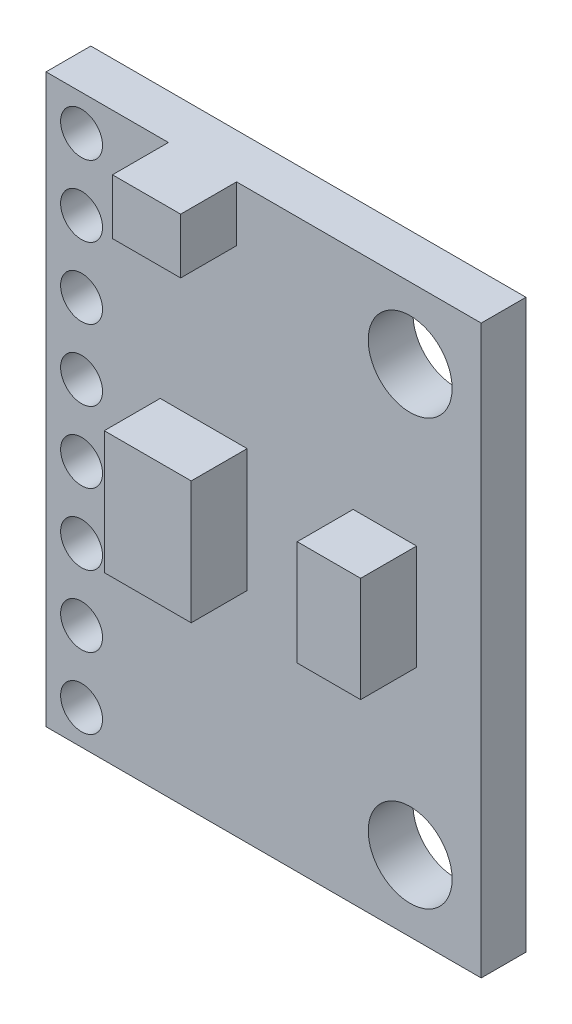
from build123d import *

# Parameters (mm, degrees)
SKETCH_1_W      = 15.56
SKETCH_1_H      = 20.28
SKETCH_1_R      = 1.5
SKETCH_1_R_2    = 0.75
EXTRUDE_1_DEPTH = 1.6
SKETCH_2_W      = 2.267131812
SKETCH_2_H      = 3.757883692
SKETCH_2_W_2    = 3.109101674
SKETCH_2_H_2    = 4.394457387
SKETCH_2_W_3    = 2.437826046
SKETCH_2_H_3    = 1.976096162
EXTRUDE_2_DEPTH = 2


with BuildPart() as part:
    # 草图1 → 凸台-拉伸1 (new body)
    with BuildSketch(Plane.XY):
        Rectangle(SKETCH_1_W, SKETCH_1_H)
        with Locations((5.24, 7.6)):
            Circle(SKETCH_1_R, mode=Mode.SUBTRACT)
        with Locations((5.24, -7.6)):
            Circle(SKETCH_1_R, mode=Mode.SUBTRACT)
        with Locations((-6.51, 8.87)):
            Circle(SKETCH_1_R_2, mode=Mode.SUBTRACT)
        with Locations((-6.51, 6.33)):
            Circle(SKETCH_1_R_2, mode=Mode.SUBTRACT)
        with Locations((-6.51, 3.79)):
            Circle(SKETCH_1_R_2, mode=Mode.SUBTRACT)
        with Locations((-6.51, 1.25)):
            Circle(SKETCH_1_R_2, mode=Mode.SUBTRACT)
        with Locations((-6.51, -1.29)):
            Circle(SKETCH_1_R_2, mode=Mode.SUBTRACT)
        with Locations((-6.51, -3.83)):
            Circle(SKETCH_1_R_2, mode=Mode.SUBTRACT)
        with Locations((-6.51, -6.37)):
            Circle(SKETCH_1_R_2, mode=Mode.SUBTRACT)
        with Locations((-6.51, -8.91)):
            Circle(SKETCH_1_R_2, mode=Mode.SUBTRACT)
    extrude(amount=EXTRUDE_1_DEPTH)

    # 草图2 → 凸台-拉伸2 (add)
    with BuildSketch(Plane.XY.offset(1.6)):
        with Locations((4.335037476, 0.202355131)):
            Rectangle(SKETCH_2_W, SKETCH_2_H)
        with Locations((-2.143513608, -0.128846081)):
            Rectangle(SKETCH_2_W_2, SKETCH_2_H_2)
        with Locations((-2.18551331, 9.151951919)):
            Rectangle(SKETCH_2_W_3, SKETCH_2_H_3)
    extrude(amount=EXTRUDE_2_DEPTH)


solid = part.part
